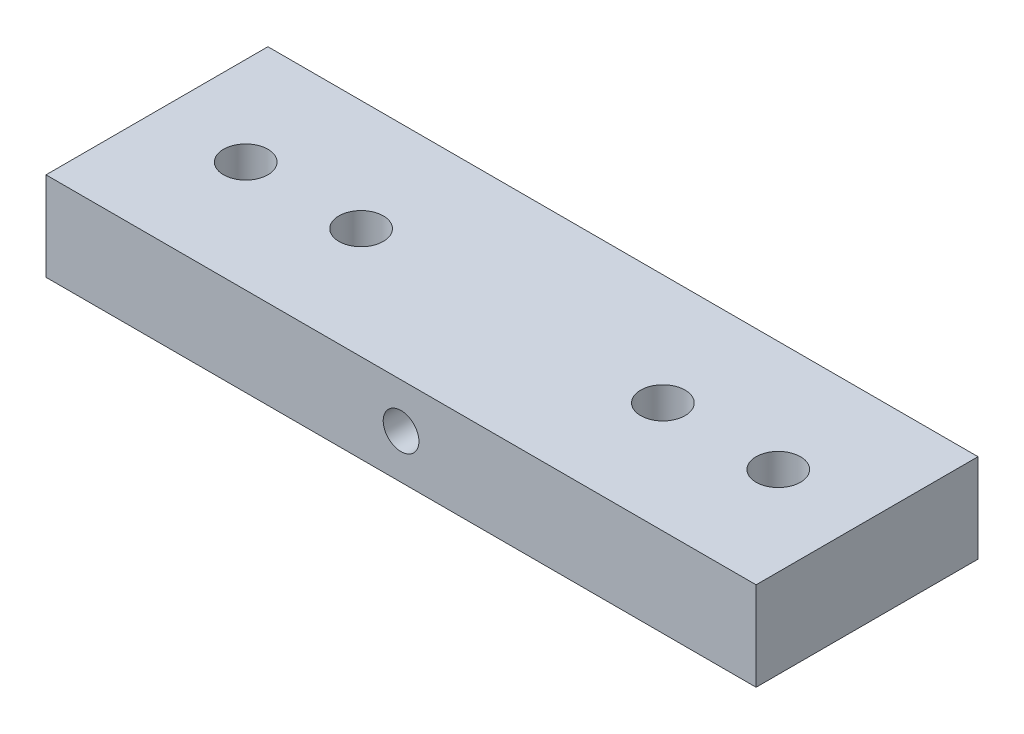
from build123d import *

# Parameters (mm, degrees)
SKETCH1_W               = 101.6
SKETCH1_H               = 31.75
SKETCH1_R               = 3.175
BOSS_EXTRUDE1_DEPTH     = 12.7
F_1_4_20_TAPPED_HOLE1_D = 5.1054


with BuildPart() as part:
    # Sketch1 → Boss-Extrude1 (new body)
    with BuildSketch(Plane(origin=(0, 0, 0), x_dir=(1, 0, 0), z_dir=(0, 1, 0))):
        with Locations((19.385978836, 15.875)):
            Rectangle(SKETCH1_W, SKETCH1_H)
        with Locations((-18.714021164, 15.875)):
            Circle(SKETCH1_R, mode=Mode.SUBTRACT)
        with Locations((57.485978836, 15.875)):
            Circle(SKETCH1_R, mode=Mode.SUBTRACT)
        with Locations((-2.204021164, 15.875)):
            Circle(SKETCH1_R, mode=Mode.SUBTRACT)
        with Locations((40.975978836, 15.875)):
            Circle(SKETCH1_R, mode=Mode.SUBTRACT)
    extrude(amount=BOSS_EXTRUDE1_DEPTH)

    # 1/4-20 Tapped Hole1 (through all)
    with Locations(Plane(origin=(19.385978836, 6.35, 0), x_dir=(1, 0, 0), z_dir=(0, 0, 1))):
        with Locations((0, 0)):
            Hole(F_1_4_20_TAPPED_HOLE1_D / 2)


solid = part.part
